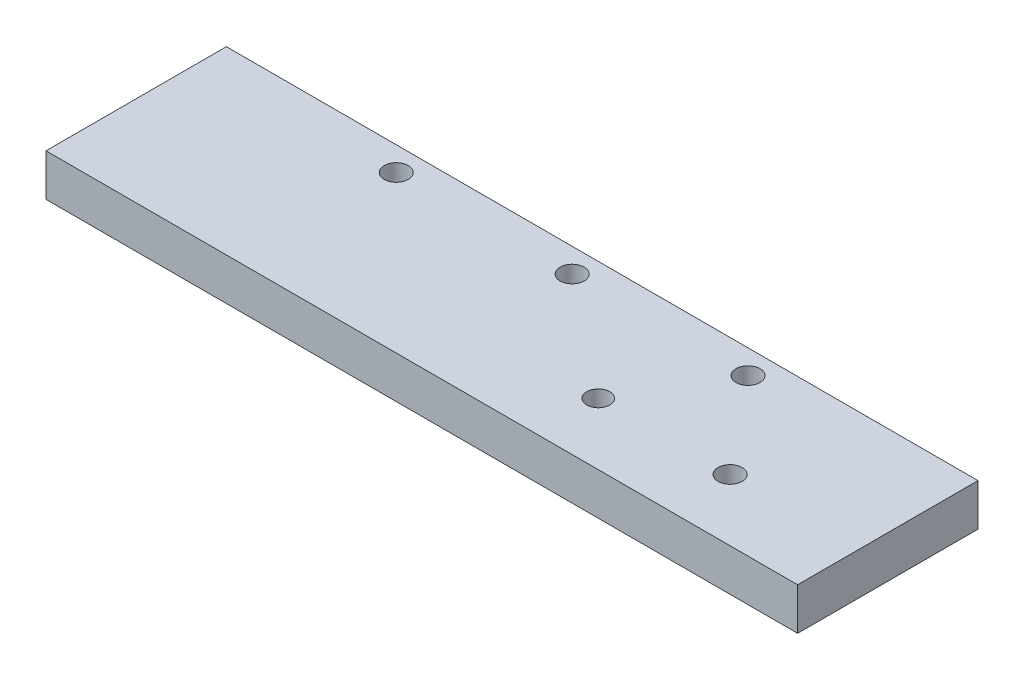
from build123d import *

# Parameters (mm, degrees)
SKETCH1_W           = 125
SKETCH1_H           = 30
BOSS_EXTRUDE1_DEPTH = 7
SKETCH2_R           = 2
SKETCH2_R_2         = 1.919016817
SKETCH2_R_3         = 2.005486385
CUT_EXTRUDE1_DEPTH  = 10


with BuildPart() as part:
    # Sketch1 → Boss-Extrude1 (new body)
    with BuildSketch(Plane(origin=(0, 0, 0), x_dir=(1, 0, 0), z_dir=(0, 1, 0))):
        with Locations((-40.010460251, 50.167364017)):
            Rectangle(SKETCH1_W, SKETCH1_H)
    extrude(amount=BOSS_EXTRUDE1_DEPTH)

    # Sketch2 → Cut-Extrude1 (cut)
    with BuildSketch(Plane.XZ):
        with Locations((-70.260460251, -61.167364017)):
            Circle(SKETCH2_R)
        with Locations((-41.010460251, -61.167364017)):
            Circle(SKETCH2_R)
        with Locations((-11.760460251, -61.167364017)):
            Circle(SKETCH2_R)
        with Locations((-20.929683781, -45.435395695)):
            Circle(SKETCH2_R_2)
        with Locations((0.98873589, -45.435395695)):
            Circle(SKETCH2_R_3)
    extrude(amount=-CUT_EXTRUDE1_DEPTH, mode=Mode.SUBTRACT)


solid = part.part
